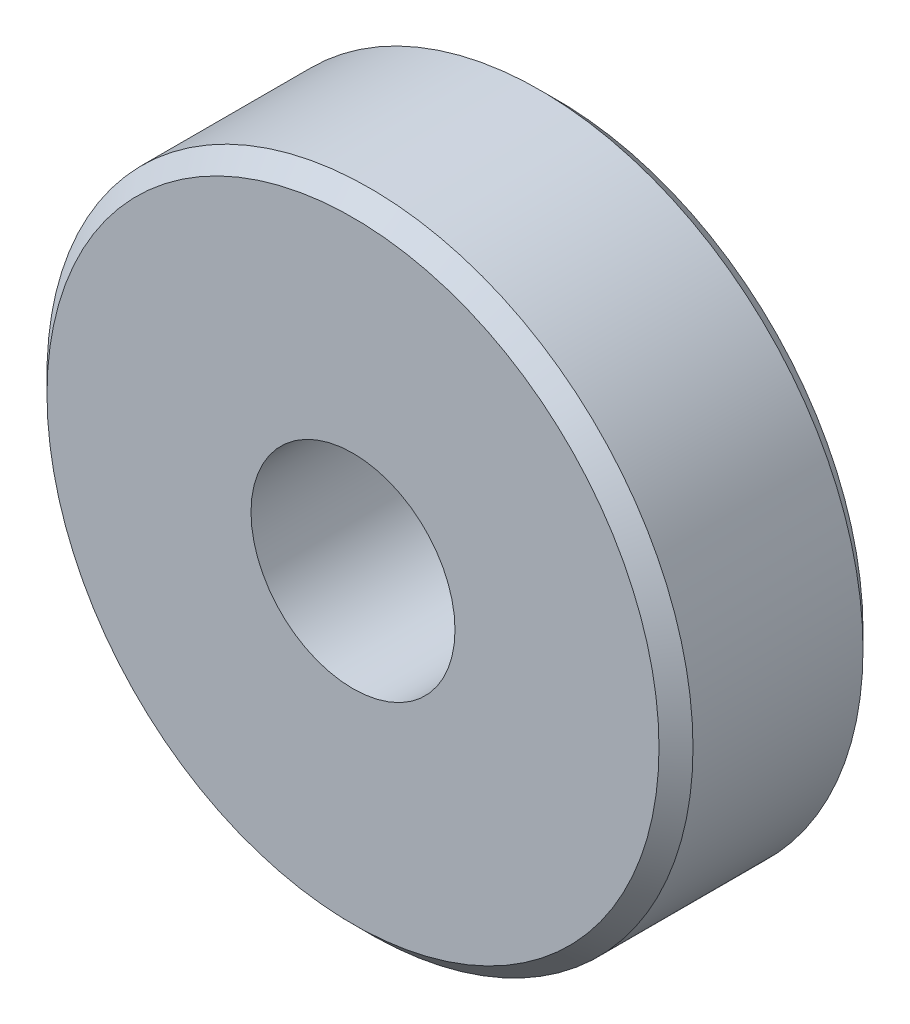
from build123d import *

# Parameters (mm, degrees)
SKETCH1_R           = 9.5
SKETCH1_R_2         = 3
BOSS_EXTRUDE1_DEPTH = 3
CHAMFER1_SIZE       = 0.5


with BuildPart() as part:
    # Sketch1 → Boss-Extrude1 (new body, symmetric)
    with BuildSketch(Plane.XY):
        Circle(SKETCH1_R)
        Circle(SKETCH1_R_2, mode=Mode.SUBTRACT)
    extrude(amount=BOSS_EXTRUDE1_DEPTH, both=True)

    # Chamfer1
    chamfer1_edges = [part.edges().sort_by_distance(p)[0] for p in [
        (-9.5, 0, -3),
        (-9.5, 0, 3),
    ]]
    chamfer(chamfer1_edges, length=CHAMFER1_SIZE)


solid = part.part
